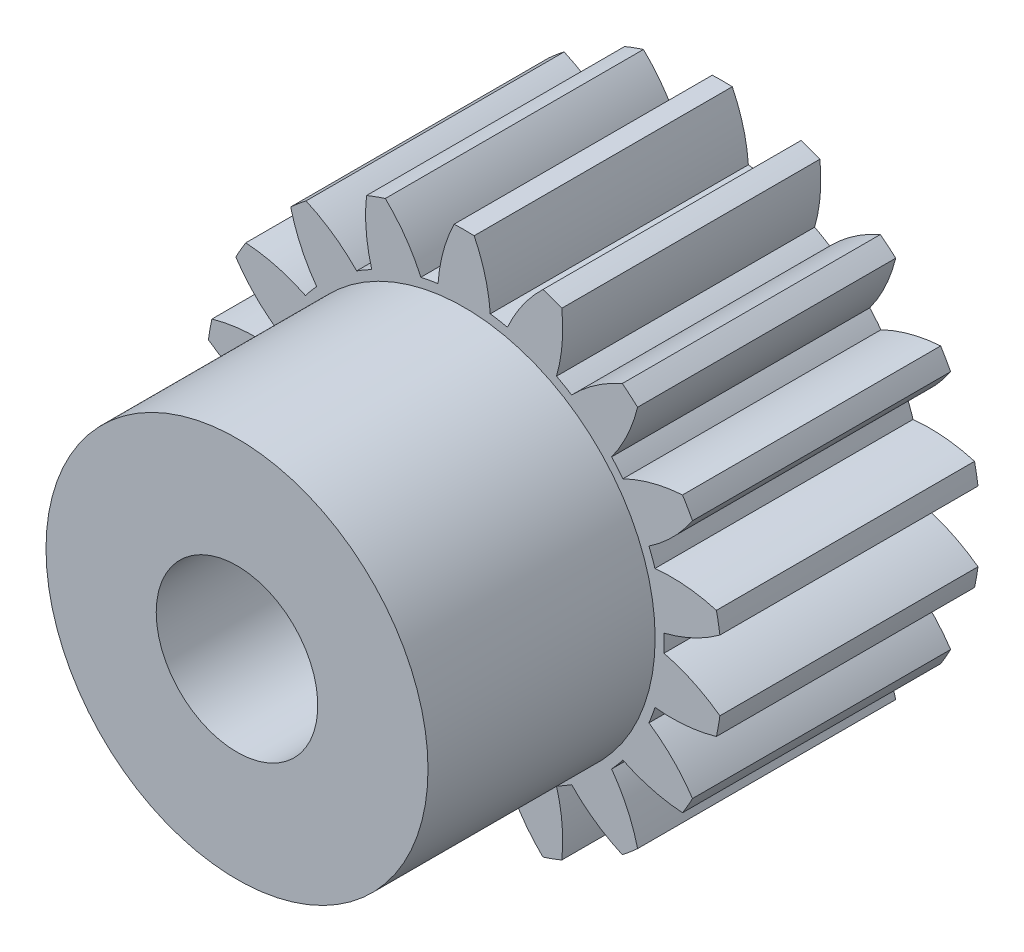
from build123d import *

# Parameters (mm, degrees)
SKETCH1_W           = 12.6999746
SKETCH1_H           = 12.6999746
CUT_EXTRUDE1_DEPTH  = 13.6999746
CUT_EXTRUDE2_DEPTH  = 13.6999746
CUT_EXTRUDE3_DEPTH  = 13.6999746
CUT_EXTRUDE4_DEPTH  = 13.6999746
CUT_EXTRUDE5_DEPTH  = 13.6999746
CUT_EXTRUDE6_DEPTH  = 13.6999746
CUT_EXTRUDE7_DEPTH  = 13.6999746
CUT_EXTRUDE8_DEPTH  = 13.6999746
CUT_EXTRUDE9_DEPTH  = 13.6999746
CUT_EXTRUDE10_DEPTH = 13.6999746
CUT_EXTRUDE11_DEPTH = 13.6999746
CUT_EXTRUDE12_DEPTH = 13.6999746
CUT_EXTRUDE13_DEPTH = 13.6999746
CUT_EXTRUDE14_DEPTH = 13.6999746
CUT_EXTRUDE15_DEPTH = 13.6999746
CUT_EXTRUDE16_DEPTH = 13.6999746
CUT_EXTRUDE17_DEPTH = 13.6999746
CUT_EXTRUDE18_DEPTH = 13.6999746
SKETCH20_W          = 9.398
SKETCH20_H          = 11.176
HOLE1_D             = 7.9502
HOLE1_DEPTH         = 23.8759746


with BuildPart() as part:
    # Sketch1 → Revolve1 (revolve)
    with BuildSketch(Plane(origin=(0, 0, 0), x_dir=(1, 0, 0), z_dir=(0, 1, 0))):
        with Locations((6.3499873, 6.3499873)):
            Rectangle(SKETCH1_W, SKETCH1_H)
    revolve(axis=Axis((0, 0, -12.6999746), (0, 0, 1)))

    # Sketch2 → Cut-Extrude1 (cut, through all)
    with BuildSketch(Plane(origin=(0, 0, -12.6999746), x_dir=(-1, 0, 0), z_dir=(0, 0, -1))):
        with BuildLine():
            ThreePointArc((8.534413947, 9.404952601), (8.029135964, 7.965277069), (7.256565826, 6.649561727))
            ThreePointArc((7.256565826, 6.649561727), (7.539777352, 6.326624395), (7.808629375, 5.99163801))
            ThreePointArc((7.808629375, 5.99163801), (9.238511441, 6.523999499), (10.744055667, 6.771604142))
            ThreePointArc((10.744055667, 6.771604142), (9.72874497, 8.163386316), (8.534413947, 9.404952601))
        make_face()
    extrude(amount=-CUT_EXTRUDE1_DEPTH, mode=Mode.SUBTRACT)

    # Sketch3 → Cut-Extrude2 (cut, through all)
    with BuildSketch(Plane(origin=(0, 0, -12.6999746), x_dir=(-1, 0, 0), z_dir=(0, 0, -1))):
        with BuildLine():
            ThreePointArc((11.236409045, 5.918823076), (10.269205021, 4.738785851), (9.093225414, 3.766652403))
            ThreePointArc((9.093225414, 3.766652403), (9.248906122, 3.366326528), (9.386972293, 2.959589486))
            ThreePointArc((9.386972293, 2.959589486), (10.912700272, 2.97079718), (12.412134847, 2.688542984))
            ThreePointArc((12.412134847, 2.688542984), (11.934072416, 4.343647133), (11.236409045, 5.918823076))
        make_face()
    extrude(amount=-CUT_EXTRUDE2_DEPTH, mode=Mode.SUBTRACT)

    # Sketch4 → Cut-Extrude3 (cut, through all)
    with BuildSketch(Plane(origin=(0, 0, -12.6999746), x_dir=(-1, 0, 0), z_dir=(0, 0, -1))):
        with BuildLine():
            ThreePointArc((12.583127381, 1.718796137), (11.270656395, 0.940727123), (9.833107815, 0.429429208))
            ThreePointArc((9.833107815, 0.429429208), (9.842480315, 0), (9.833107815, -0.429429208))
            ThreePointArc((9.833107815, -0.429429208), (11.270656395, -0.940727123), (12.583127381, -1.718796137))
            ThreePointArc((12.583127381, -1.718796137), (12.6999746, 0), (12.583127381, 1.718796137))
        make_face()
    extrude(amount=-CUT_EXTRUDE3_DEPTH, mode=Mode.SUBTRACT)

    # Sketch5 → Cut-Extrude4 (cut, through all)
    with BuildSketch(Plane(origin=(0, 0, -12.6999746), x_dir=(-1, 0, 0), z_dir=(0, 0, -1))):
        with BuildLine():
            ThreePointArc((12.412134847, -2.688542984), (10.912700272, -2.97079718), (9.386972293, -2.959589486))
            ThreePointArc((9.386972293, -2.959589486), (9.248906122, -3.366326528), (9.093225414, -3.766652403))
            ThreePointArc((9.093225414, -3.766652403), (10.269205021, -4.738785851), (11.236409045, -5.918823076))
            ThreePointArc((11.236409045, -5.918823076), (11.934072416, -4.343647133), (12.412134847, -2.688542984))
        make_face()
    extrude(amount=-CUT_EXTRUDE4_DEPTH, mode=Mode.SUBTRACT)

    # Sketch6 → Cut-Extrude5 (cut, through all)
    with BuildSketch(Plane(origin=(0, 0, -12.6999746), x_dir=(-1, 0, 0), z_dir=(0, 0, -1))):
        with BuildLine():
            ThreePointArc((10.744055667, -6.771604142), (9.238511441, -6.523999499), (7.808629375, -5.99163801))
            ThreePointArc((7.808629375, -5.99163801), (7.539777352, -6.326624395), (7.256565826, -6.649561727))
            ThreePointArc((7.256565826, -6.649561727), (8.029135964, -7.965277069), (8.534413947, -9.404952601))
            ThreePointArc((8.534413947, -9.404952601), (9.72874497, -8.163386316), (10.744055667, -6.771604142))
        make_face()
    extrude(amount=-CUT_EXTRUDE5_DEPTH, mode=Mode.SUBTRACT)

    # Sketch7 → Cut-Extrude6 (cut, through all)
    with BuildSketch(Plane(origin=(0, 0, -12.6999746), x_dir=(-1, 0, 0), z_dir=(0, 0, -1))):
        with BuildLine():
            ThreePointArc((7.780084809, -10.037909903), (6.450021784, -9.290311195), (5.288450511, -8.301006562))
            ThreePointArc((5.288450511, -8.301006562), (4.921240157, -8.523837989), (4.544657304, -8.73043577))
            ThreePointArc((4.544657304, -8.73043577), (4.820634612, -10.231038317), (4.803042572, -11.756706039))
            ThreePointArc((4.803042572, -11.756706039), (6.3499873, -10.998500631), (7.780084809, -10.037909903))
        make_face()
    extrude(amount=-CUT_EXTRUDE6_DEPTH, mode=Mode.SUBTRACT)

    # Sketch8 → Cut-Extrude7 (cut, through all)
    with BuildSketch(Plane(origin=(0, 0, -12.6999746), x_dir=(-1, 0, 0), z_dir=(0, 0, -1))):
        with BuildLine():
            ThreePointArc((3.8777209, -12.093495585), (2.883564308, -10.936074249), (2.130406467, -9.609151213))
            ThreePointArc((2.130406467, -9.609151213), (1.70912877, -9.692950923), (1.284596039, -9.758290412))
            ThreePointArc((1.284596039, -9.758290412), (1.03069358, -11.26278535), (0.492353378, -12.690427219))
            ThreePointArc((0.492353378, -12.690427219), (2.205327446, -12.507033449), (3.8777209, -12.093495585))
        make_face()
    extrude(amount=-CUT_EXTRUDE7_DEPTH, mode=Mode.SUBTRACT)

    # Sketch9 → Cut-Extrude8 (cut, through all)
    with BuildSketch(Plane(origin=(0, 0, -12.6999746), x_dir=(-1, 0, 0), z_dir=(0, 0, -1))):
        with BuildLine():
            ThreePointArc((-0.492353378, -12.690427219), (-1.03069358, -11.26278535), (-1.284596039, -9.758290412))
            ThreePointArc((-1.284596039, -9.758290412), (-1.70912877, -9.692950923), (-2.130406467, -9.609151213))
            ThreePointArc((-2.130406467, -9.609151213), (-2.883564308, -10.936074249), (-3.8777209, -12.093495585))
            ThreePointArc((-3.8777209, -12.093495585), (-2.205327446, -12.507033449), (-0.492353378, -12.690427219))
        make_face()
    extrude(amount=-CUT_EXTRUDE8_DEPTH, mode=Mode.SUBTRACT)

    # Sketch10 → Cut-Extrude9 (cut, through all)
    with BuildSketch(Plane(origin=(0, 0, -12.6999746), x_dir=(-1, 0, 0), z_dir=(0, 0, -1))):
        with BuildLine():
            ThreePointArc((-4.803042572, -11.756706039), (-4.820634612, -10.231038317), (-4.544657304, -8.73043577))
            ThreePointArc((-4.544657304, -8.73043577), (-4.921240157, -8.523837989), (-5.288450511, -8.301006562))
            ThreePointArc((-5.288450511, -8.301006562), (-6.450021784, -9.290311195), (-7.780084809, -10.037909903))
            ThreePointArc((-7.780084809, -10.037909903), (-6.3499873, -10.998500631), (-4.803042572, -11.756706039))
        make_face()
    extrude(amount=-CUT_EXTRUDE9_DEPTH, mode=Mode.SUBTRACT)

    # Sketch11 → Cut-Extrude10 (cut, through all)
    with BuildSketch(Plane(origin=(0, 0, -12.6999746), x_dir=(-1, 0, 0), z_dir=(0, 0, -1))):
        with BuildLine():
            ThreePointArc((-8.534413947, -9.404952601), (-8.029135964, -7.965277069), (-7.256565826, -6.649561727))
            ThreePointArc((-7.256565826, -6.649561727), (-7.539777352, -6.326624395), (-7.808629375, -5.99163801))
            ThreePointArc((-7.808629375, -5.99163801), (-9.238511441, -6.523999499), (-10.744055667, -6.771604142))
            ThreePointArc((-10.744055667, -6.771604142), (-9.72874497, -8.163386316), (-8.534413947, -9.404952601))
        make_face()
    extrude(amount=-CUT_EXTRUDE10_DEPTH, mode=Mode.SUBTRACT)

    # Sketch12 → Cut-Extrude11 (cut, through all)
    with BuildSketch(Plane(origin=(0, 0, -12.6999746), x_dir=(-1, 0, 0), z_dir=(0, 0, -1))):
        with BuildLine():
            ThreePointArc((-11.236409045, -5.918823076), (-10.269205021, -4.738785851), (-9.093225414, -3.766652403))
            ThreePointArc((-9.093225414, -3.766652403), (-9.248906122, -3.366326528), (-9.386972293, -2.959589486))
            ThreePointArc((-9.386972293, -2.959589486), (-10.912700272, -2.97079718), (-12.412134847, -2.688542984))
            ThreePointArc((-12.412134847, -2.688542984), (-11.934072416, -4.343647133), (-11.236409045, -5.918823076))
        make_face()
    extrude(amount=-CUT_EXTRUDE11_DEPTH, mode=Mode.SUBTRACT)

    # Sketch13 → Cut-Extrude12 (cut, through all)
    with BuildSketch(Plane(origin=(0, 0, -12.6999746), x_dir=(-1, 0, 0), z_dir=(0, 0, -1))):
        with BuildLine():
            ThreePointArc((-12.583127381, -1.718796137), (-11.270656395, -0.940727123), (-9.833107815, -0.429429208))
            ThreePointArc((-9.833107815, -0.429429208), (-9.842480315, 0), (-9.833107815, 0.429429208))
            ThreePointArc((-9.833107815, 0.429429208), (-11.270656395, 0.940727123), (-12.583127381, 1.718796137))
            ThreePointArc((-12.583127381, 1.718796137), (-12.6999746, 0), (-12.583127381, -1.718796137))
        make_face()
    extrude(amount=-CUT_EXTRUDE12_DEPTH, mode=Mode.SUBTRACT)

    # Sketch14 → Cut-Extrude13 (cut, through all)
    with BuildSketch(Plane(origin=(0, 0, -12.6999746), x_dir=(-1, 0, 0), z_dir=(0, 0, -1))):
        with BuildLine():
            ThreePointArc((-12.412134847, 2.688542984), (-10.912700272, 2.97079718), (-9.386972293, 2.959589486))
            ThreePointArc((-9.386972293, 2.959589486), (-9.248906122, 3.366326528), (-9.093225414, 3.766652403))
            ThreePointArc((-9.093225414, 3.766652403), (-10.269205021, 4.738785851), (-11.236409045, 5.918823076))
            ThreePointArc((-11.236409045, 5.918823076), (-11.934072416, 4.343647133), (-12.412134847, 2.688542984))
        make_face()
    extrude(amount=-CUT_EXTRUDE13_DEPTH, mode=Mode.SUBTRACT)

    # Sketch15 → Cut-Extrude14 (cut, through all)
    with BuildSketch(Plane(origin=(0, 0, -12.6999746), x_dir=(-1, 0, 0), z_dir=(0, 0, -1))):
        with BuildLine():
            ThreePointArc((-10.744055667, 6.771604142), (-9.238511441, 6.523999499), (-7.808629375, 5.99163801))
            ThreePointArc((-7.808629375, 5.99163801), (-7.539777352, 6.326624395), (-7.256565826, 6.649561727))
            ThreePointArc((-7.256565826, 6.649561727), (-8.029135964, 7.965277069), (-8.534413947, 9.404952601))
            ThreePointArc((-8.534413947, 9.404952601), (-9.72874497, 8.163386316), (-10.744055667, 6.771604142))
        make_face()
    extrude(amount=-CUT_EXTRUDE14_DEPTH, mode=Mode.SUBTRACT)

    # Sketch16 → Cut-Extrude15 (cut, through all)
    with BuildSketch(Plane(origin=(0, 0, -12.6999746), x_dir=(-1, 0, 0), z_dir=(0, 0, -1))):
        with BuildLine():
            ThreePointArc((-7.780084809, 10.037909903), (-6.450021784, 9.290311195), (-5.288450511, 8.301006562))
            ThreePointArc((-5.288450511, 8.301006562), (-4.921240158, 8.523837989), (-4.544657304, 8.73043577))
            ThreePointArc((-4.544657304, 8.73043577), (-4.820634612, 10.231038317), (-4.803042572, 11.756706039))
            ThreePointArc((-4.803042572, 11.756706039), (-6.3499873, 10.998500631), (-7.780084809, 10.037909903))
        make_face()
    extrude(amount=-CUT_EXTRUDE15_DEPTH, mode=Mode.SUBTRACT)

    # Sketch17 → Cut-Extrude16 (cut, through all)
    with BuildSketch(Plane(origin=(0, 0, -12.6999746), x_dir=(-1, 0, 0), z_dir=(0, 0, -1))):
        with BuildLine():
            ThreePointArc((-3.8777209, 12.093495585), (-2.883564308, 10.936074249), (-2.130406467, 9.609151213))
            ThreePointArc((-2.130406467, 9.609151213), (-1.70912877, 9.692950923), (-1.284596039, 9.758290412))
            ThreePointArc((-1.284596039, 9.758290412), (-1.03069358, 11.26278535), (-0.492353378, 12.690427219))
            ThreePointArc((-0.492353378, 12.690427219), (-2.205327446, 12.507033449), (-3.8777209, 12.093495585))
        make_face()
    extrude(amount=-CUT_EXTRUDE16_DEPTH, mode=Mode.SUBTRACT)

    # Sketch18 → Cut-Extrude17 (cut, through all)
    with BuildSketch(Plane(origin=(0, 0, -12.6999746), x_dir=(-1, 0, 0), z_dir=(0, 0, -1))):
        with BuildLine():
            ThreePointArc((0.492353378, 12.690427219), (1.03069358, 11.26278535), (1.284596039, 9.758290412))
            ThreePointArc((1.284596039, 9.758290412), (1.70912877, 9.692950923), (2.130406467, 9.609151213))
            ThreePointArc((2.130406467, 9.609151213), (2.883564308, 10.936074249), (3.8777209, 12.093495585))
            ThreePointArc((3.8777209, 12.093495585), (2.205327446, 12.507033449), (0.492353378, 12.690427219))
        make_face()
    extrude(amount=-CUT_EXTRUDE17_DEPTH, mode=Mode.SUBTRACT)

    # Sketch19 → Cut-Extrude18 (cut, through all)
    with BuildSketch(Plane(origin=(0, 0, -12.6999746), x_dir=(-1, 0, 0), z_dir=(0, 0, -1))):
        with BuildLine():
            ThreePointArc((4.803042572, 11.756706039), (4.820634612, 10.231038317), (4.544657304, 8.73043577))
            ThreePointArc((4.544657304, 8.73043577), (4.921240158, 8.523837989), (5.288450511, 8.301006562))
            ThreePointArc((5.288450511, 8.301006562), (6.450021784, 9.290311195), (7.780084809, 10.037909903))
            ThreePointArc((7.780084809, 10.037909903), (6.3499873, 10.998500631), (4.803042572, 11.756706039))
        make_face()
    extrude(amount=-CUT_EXTRUDE18_DEPTH, mode=Mode.SUBTRACT)

    # Sketch20 → Revolve2 (revolve)
    with BuildSketch(Plane(origin=(0, 0, 0), x_dir=(1, 0, 0), z_dir=(0, 1, 0))):
        with Locations((4.699, -5.588)):
            Rectangle(SKETCH20_W, SKETCH20_H)
    revolve(axis=Axis((0, 0, 0), (0, 0, 1)))

    # Hole1
    with Locations(Plane(origin=(0, 0, -12.6999746), x_dir=(-1, 0, 0), z_dir=(0, 0, -1))):
        with Locations((0, 0)):
            Hole(HOLE1_D / 2, depth=HOLE1_DEPTH)


solid = part.part
